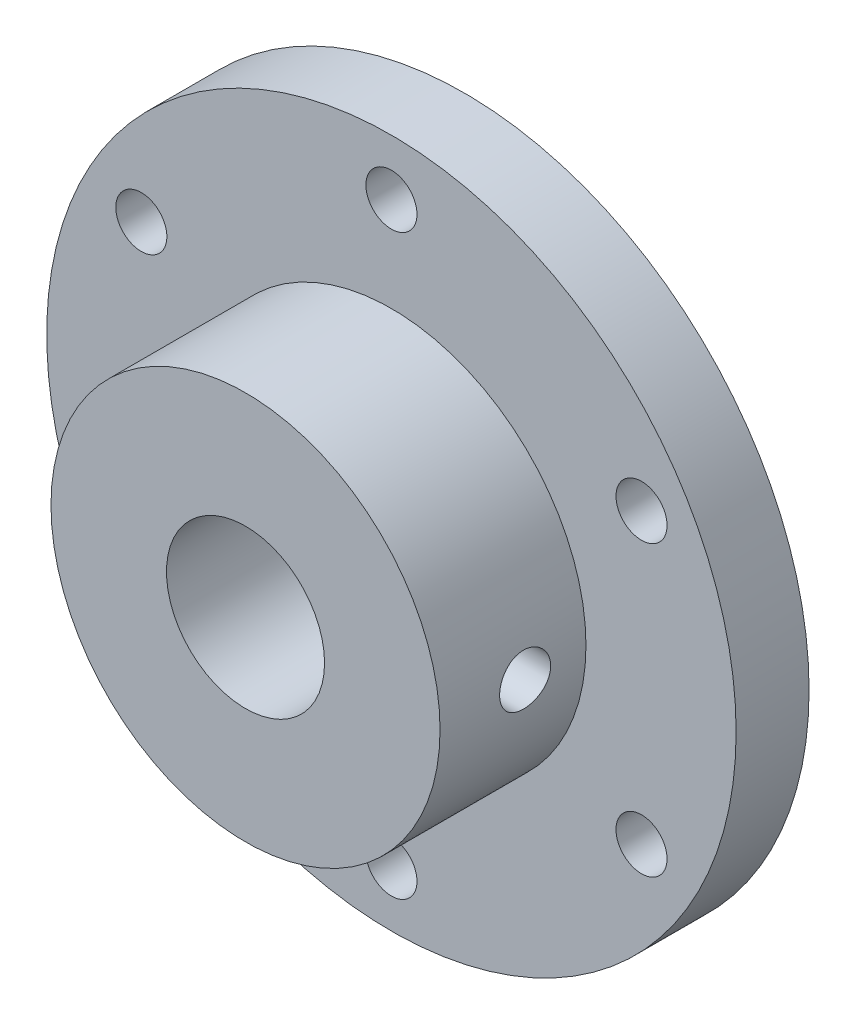
from build123d import *

# Parameters (mm, degrees)
SKETCH_1_R               = 28.35
EXTRUDE_1_DEPTH          = 6
SKETCH_2_R               = 16
EXTRUDE_2_DEPTH          = 12
SKETCH_3_R               = 6.5
CUT_EXTRUDE_1_DEPTH      = 44.948208155
HOLE_WIZARD_M5_2_D       = 4.2
PATTERN_CIRCULAR_1_COUNT = 6
CUT_EXTRUDE_3_REACH      = 57.63
SKETCH_6_R               = 2.1


with BuildPart() as part:
    # 草圖1 → 填料-伸長1 (new body)
    with BuildSketch(Plane.XY):
        Circle(SKETCH_1_R)
    extrude(amount=EXTRUDE_1_DEPTH)

    # 草圖2 → 填料-伸長2 (add)
    with BuildSketch(Plane.XY.offset(6)):
        Circle(SKETCH_2_R)
    extrude(amount=EXTRUDE_2_DEPTH)

    # 草圖3 → 除料-伸長1 (cut, through all)
    with BuildSketch(Plane.XY.offset(18)):
        Circle(SKETCH_3_R)
    extrude(amount=-CUT_EXTRUDE_1_DEPTH, mode=Mode.SUBTRACT)

    # M5 螺紋孔2 (through all)
    with Locations(Plane(origin=(0, 0, 0), x_dir=(-1, 0, 0), z_dir=(0, 0, -1))):
        with Locations((0, 23.75)):
            hole_wizard_m5_2 = Hole(HOLE_WIZARD_M5_2_D / 2)

    # 環狀複製排列1: M5 螺紋孔2 ×6 about axis
    pattern_circular_1_axis = Axis((0, 0, 6), (0, 0, 1))
    for i in range(1, PATTERN_CIRCULAR_1_COUNT):
        add(hole_wizard_m5_2.rotate(pattern_circular_1_axis, i * 360 / PATTERN_CIRCULAR_1_COUNT), mode=Mode.SUBTRACT)

    # 草圖6 → 除料-伸長3 (cut, up to next)
    with BuildSketch(Plane(origin=(16, 0, 0), x_dir=(0, 0, -1), z_dir=(1, 0, 0)), mode=Mode.PRIVATE) as cut_extrude_3_sk1:
        with Locations((-11, 0)):
            Circle(SKETCH_6_R)
    cut_extrude_3_tool1 = extrude(cut_extrude_3_sk1.sketch, amount=-CUT_EXTRUDE_3_REACH, mode=Mode.PRIVATE) & part.part
    add(cut_extrude_3_tool1.solids().sort_by_distance((16, 0, 11))[0], mode=Mode.SUBTRACT)


solid = part.part
